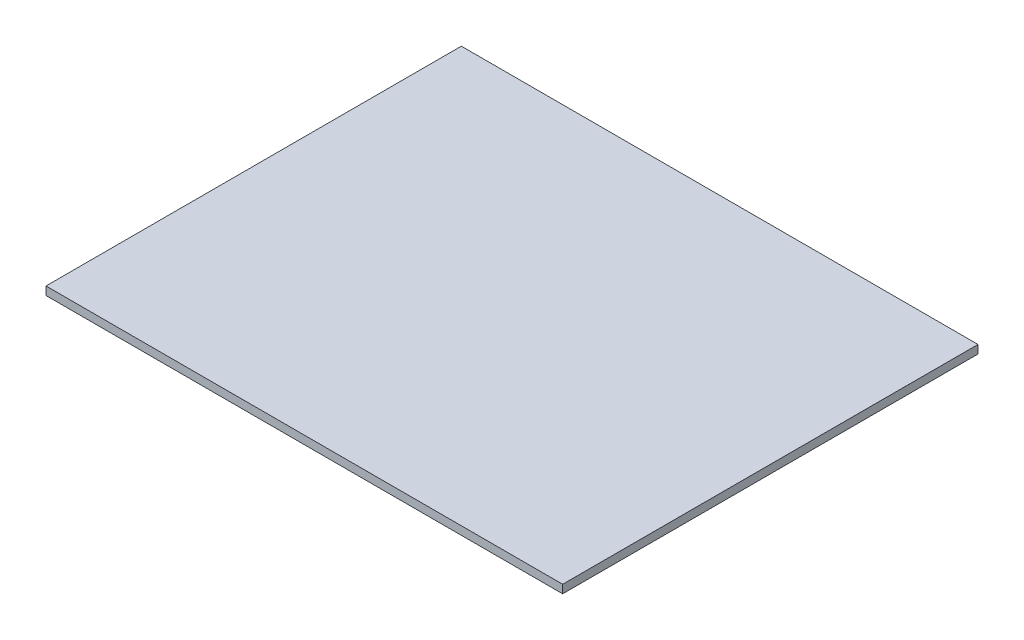
from build123d import *

# Parameters (mm, degrees)
SKETCH1_W           = 395.475
SKETCH1_H           = 317.923000032
BOSS_EXTRUDE1_DEPTH = 6.35


with BuildPart() as part:
    # Sketch1 → Boss-Extrude1 (new body)
    with BuildSketch(Plane(origin=(0, 241.45, 0), x_dir=(1, 0, 0), z_dir=(0, 1, 0))):
        with Locations((158.05, 144.737500016)):
            Rectangle(SKETCH1_W, SKETCH1_H)
    extrude(amount=BOSS_EXTRUDE1_DEPTH)


solid = part.part
